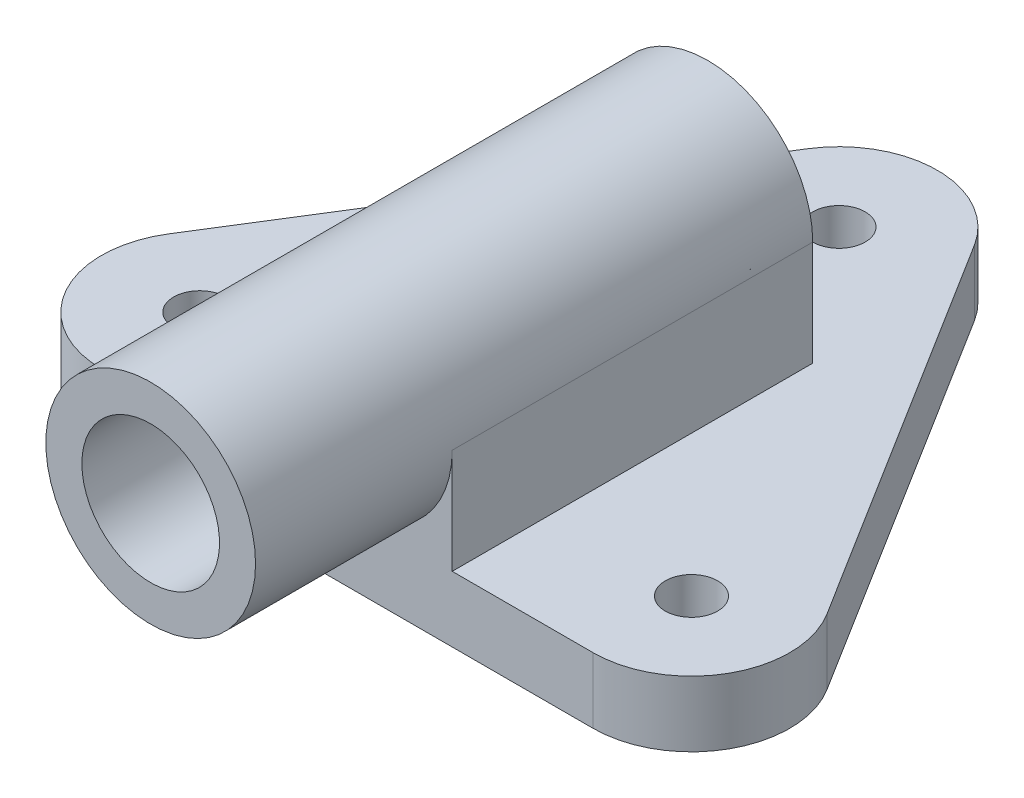
from build123d import *

# Parameters (mm, degrees)
SKETCH2_R               = 4
BOSS_EXTRUDE1_DEPTH     = 10
BOSS_EXTRUDE2_DEPTH     = 85
SKETCH5_R               = 10.5
CUT_EXTRUDE1_DEPTH      = 36
CUT_EXTRUDE1_DEPTH_BACK = 86
CUT_EXTRUDE2_DEPTH      = 30


with BuildPart() as part:
    # Sketch2 → Boss-Extrude1 (new body)
    with BuildSketch(Plane(origin=(0, 0, 0), x_dir=(1, 0, 0), z_dir=(0, 1, 0))):
        with BuildLine():
            Line((-50.21997456, -52.0500159), (-12.71997456, 7.9499841))
            ThreePointArc((-12.71997456, 7.9499841), (0, 15), (12.71997456, 7.9499841))
            Line((12.71997456, 7.9499841), (50.21997456, -52.0500159))
            ThreePointArc((50.21997456, -52.0500159), (50.619637219, -67.271527986), (37.5, -75))
            Line((37.5, -75), (-37.5, -75))
            ThreePointArc((-37.5, -75), (-50.619637219, -67.271527986), (-50.21997456, -52.0500159))
        make_face()
        Circle(SKETCH2_R, mode=Mode.SUBTRACT)
        with Locations((-37.5, -60)):
            Circle(SKETCH2_R, mode=Mode.SUBTRACT)
        with Locations((37.5, -60)):
            Circle(SKETCH2_R, mode=Mode.SUBTRACT)
    extrude(amount=BOSS_EXTRUDE1_DEPTH)

    # Sketch4 → Boss-Extrude2 (add)
    with BuildSketch(Plane.XY.offset(20)):
        with BuildLine():
            Line((16, 26), (16, 10))
            Line((16, 10), (-16, 10))
            Line((-16, 10), (-16, 26))
            ThreePointArc((-16, 26), (0, 42), (16, 26))
        make_face()
    extrude(amount=BOSS_EXTRUDE2_DEPTH)

    # Sketch5 → Cut-Extrude1 (cut, two sides)
    with BuildSketch(Plane(origin=(0, 0, 20), x_dir=(-1, 0, 0), z_dir=(0, 0, -1))) as cut_extrude1_sk:
        with Locations((0, 26)):
            Circle(SKETCH5_R)
    extrude(amount=CUT_EXTRUDE1_DEPTH, mode=Mode.SUBTRACT)
    extrude(cut_extrude1_sk.sketch, amount=-CUT_EXTRUDE1_DEPTH_BACK, mode=Mode.SUBTRACT)

    # Sketch6 → Cut-Extrude2 (cut)
    with BuildSketch(Plane.XY.offset(105)):
        with BuildLine():
            ThreePointArc((16, 26), (11.313708518, 14.68629152), (5.5e-08, 10))
            Line((5.5e-08, 10), (16, 10))
            Line((16, 10), (16, 26))
        make_face()
        with BuildLine():
            ThreePointArc((5.5e-08, 10), (-11.31370848, 14.686291482), (-16, 26))
            Line((-16, 26), (-16, 10))
            Line((-16, 10), (5.5e-08, 10))
        make_face()
    extrude(amount=-CUT_EXTRUDE2_DEPTH, mode=Mode.SUBTRACT)


solid = part.part
